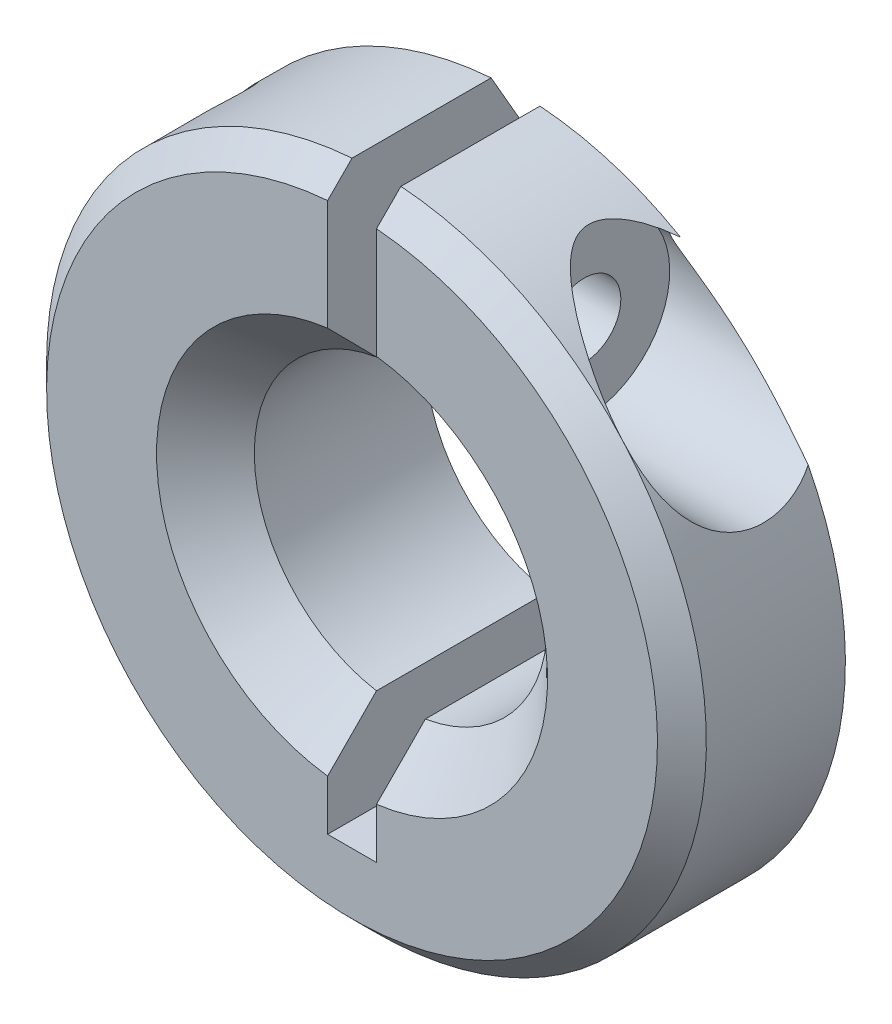
from build123d import *

# Parameters (mm, degrees)
ESQUISSE1_R             = 6.75
ESQUISSE1_R_2           = 3
EXTRUSION1_DEPTH        = 4.5
CHANFREIN1_SIZE         = 2
CHANFREIN1_SIZE2        = 1.154700538
ENL_V_START             = -4.500004
ENL_V_MAT_EXTRU_1_DEPTH = 4.500004
CHANFREIN3_SIZE         = 0.5
ESQUISSE7_W             = 0.625
ESQUISSE7_H             = 6.25
ENL_V_MAT_EXTRU_3_REACH = 8.25
ESQUISSE8_R             = 1.75
ESQUISSE9_R             = 1.75
ESQUISSE9_R_2           = 0.75
EXTRUSION2_DEPTH        = 2
CHANFREIN4_SIZE         = 1
ESQUISSE10_R            = 3
ENL_V_MAT_EXTRU_4_DEPTH = 5.5000001


with BuildPart() as part:
    # Esquisse1 → Extrusion1 (new body)
    with BuildSketch(Plane.XY):
        Circle(ESQUISSE1_R)
        Circle(ESQUISSE1_R_2, mode=Mode.SUBTRACT)
    extrude(amount=EXTRUSION1_DEPTH)

    # Chanfrein1
    chanfrein1_edges = [part.edges().sort_by_distance(p)[0] for p in [
        (-6.75, 0, 0),
    ]]
    chanfrein1_side = [part.faces().sort_by_distance(p)[0] for p in [
        (-6.559081169, 0, 0),
    ]]
    chamfer(chanfrein1_edges, length=CHANFREIN1_SIZE, length2=CHANFREIN1_SIZE2, reference=chanfrein1_side[0])

    # Esquisse3 → Enlèv. mat.-Extru.1 (cut)
    with BuildSketch(Plane.XY.offset(4.5).offset(ENL_V_START)):
        with BuildLine():
            Line((-0.5, 6.731456009), (-0.5, -5))
            Line((-0.5, -5), (0.5, -5))
            Line((0.5, -5), (0.5, 6.731456009))
            ThreePointArc((0.5, 6.731456009), (0, 6.75), (-0.5, 6.731456009))
        make_face()
    extrude(amount=ENL_V_MAT_EXTRU_1_DEPTH, mode=Mode.SUBTRACT)

    # Chanfrein3
    chanfrein3_edges = [part.edges().sort_by_distance(p)[0] for p in [
        (-4.592793268, -4.946589734, 4.5),
    ]]
    chamfer(chanfrein3_edges, length=CHANFREIN3_SIZE)

    # Esquisse7 → Trou taraudé M1.61 (revolve, cut)
    with BuildSketch(Plane(origin=(-0.5, 4.481456009, 2.25), x_dir=(0, 0, -1), z_dir=(0, 1, 0))):
        with Locations((0.3125, 3.125)):
            Rectangle(ESQUISSE7_W, ESQUISSE7_H)
    revolve(axis=Axis((5.85, 4.481456009, 2.25), (-1, 0, 0)), mode=Mode.SUBTRACT)

    # Esquisse8 → Enlèv. mat.-Extru.3 (cut, up to next)
    with BuildSketch(Plane.ZY.offset(-0.5), mode=Mode.PRIVATE) as enl_v_mat_extru_3_sk1:
        with Locations((2.25, 4.481456009)):
            Circle(ESQUISSE8_R)
    enl_v_mat_extru_3_tool1 = extrude(enl_v_mat_extru_3_sk1.sketch, amount=-ENL_V_MAT_EXTRU_3_REACH, mode=Mode.PRIVATE) & part.part
    add(enl_v_mat_extru_3_tool1.solids().sort_by_distance((0.5, 4.481456, 2.25))[0], mode=Mode.SUBTRACT)

    # Esquisse9 → Extrusion2 (add)
    with BuildSketch(Plane.ZY.offset(-0.5)):
        with Locations((2.25, 4.481456009)):
            Circle(ESQUISSE9_R)
        with Locations((2.25, 4.481456009)):
            Circle(ESQUISSE9_R_2, mode=Mode.SUBTRACT)
    extrude(amount=-EXTRUSION2_DEPTH)

    # Chanfrein4
    chanfrein4_edges = [part.edges().sort_by_distance(p)[0] for p in [
        (-3, 0, 4.5),
        (3, 0, 4.5),
    ]]
    chamfer(chanfrein4_edges, length=CHANFREIN4_SIZE)

    # Esquisse10 → Enlèv. mat.-Extru.4 (cut, through all)
    with BuildSketch(Plane.XY.offset(4.5)):
        Circle(ESQUISSE10_R)
    extrude(amount=-ENL_V_MAT_EXTRU_4_DEPTH, mode=Mode.SUBTRACT)


solid = part.part
